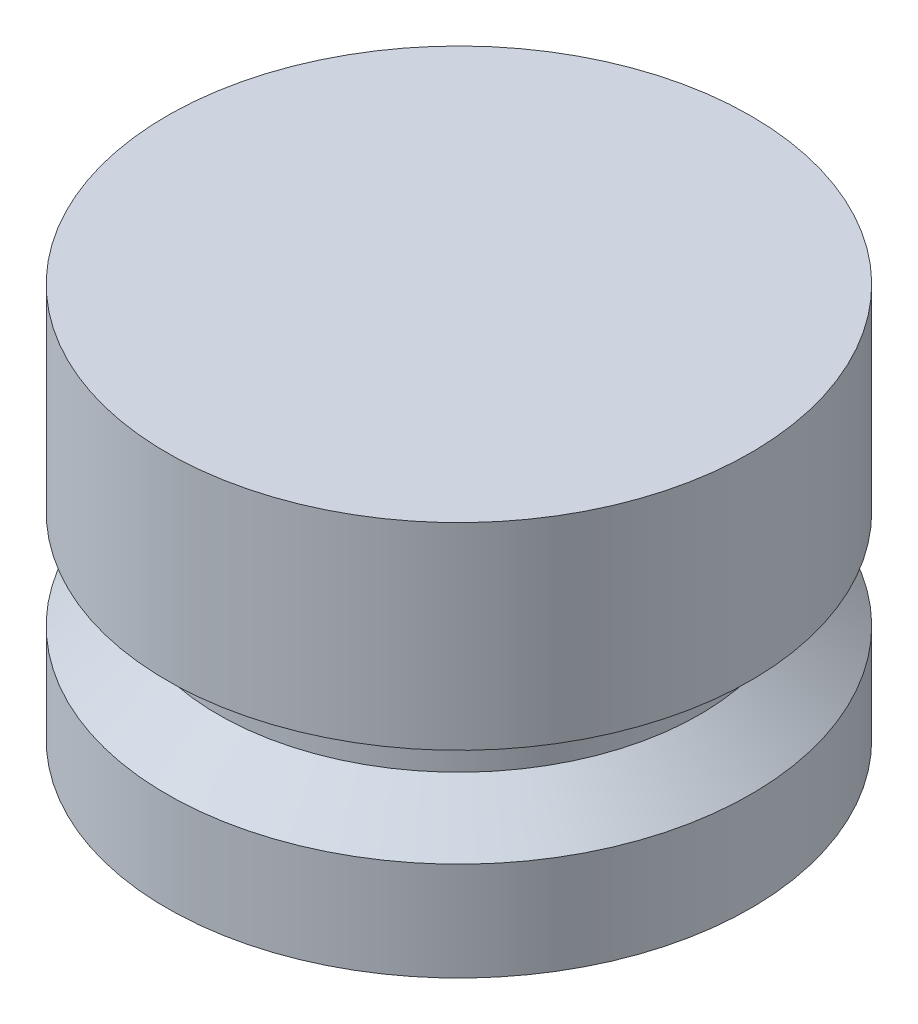
from build123d import *


with BuildPart() as part:
    # Sketch1 → Revolve1 (revolve)
    with BuildSketch(Plane.XY):
        Polygon((0, 0), (-9.398, 0), (-9.398, 3.175), (-7.747, 4.572), (-7.747, 6.35), (-9.398, 6.35), (-9.398, 12.7), (0, 12.7), align=None)
    revolve(axis=Axis((0, 0, 0), (0, 1, 0)))


solid = part.part
